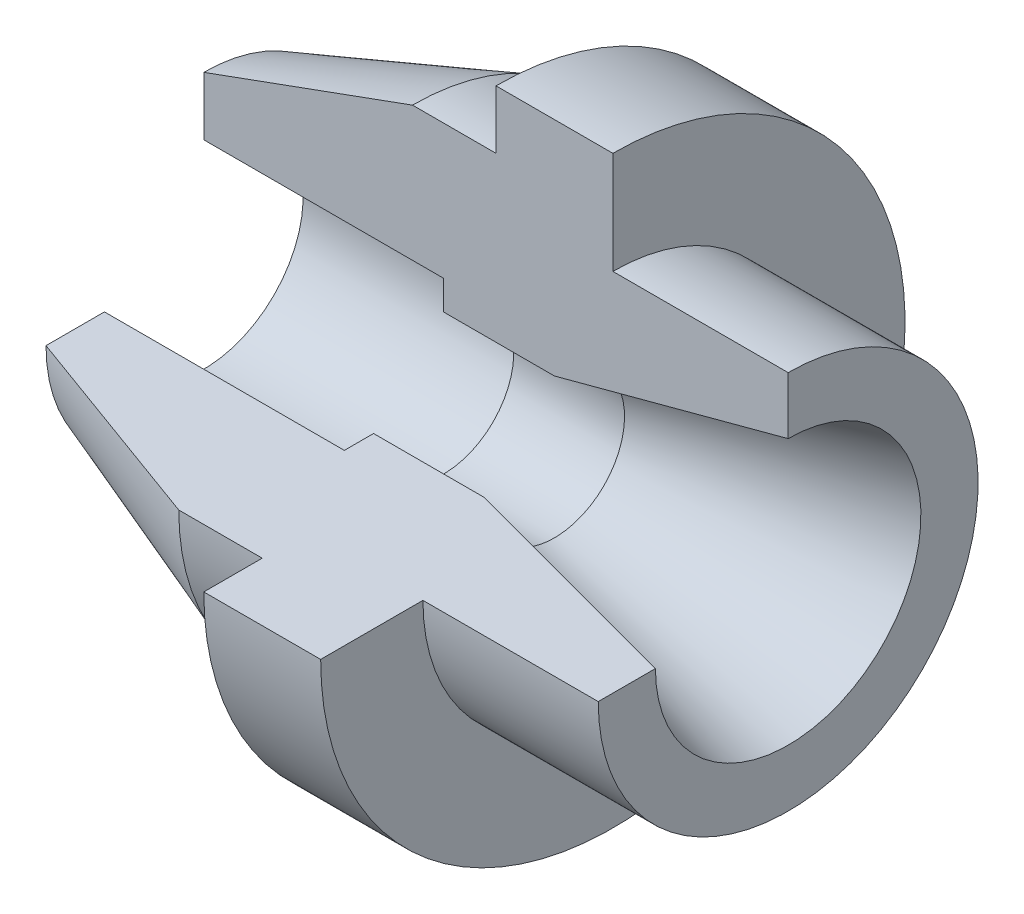
from build123d import *

# Parameters (mm, degrees)
REVOLVE1_ANGLE = 270


with BuildPart() as part:
    # Sketch2 → Revolve1 (revolve)
    with BuildSketch(Plane.XY):
        Polygon((-54.522496773, 27), (-54.522496773, 0), (45.477503227, 0), (45.477503227, 32.5), (15.477503227, 32.5), (15.477503227, 50), (-4.522496773, 50), (-4.522496773, 40), (-18.80529032, 40), align=None)
    revolve(axis=Axis((88.99, 0, 0), (-1, 0, 0)), revolution_arc=REVOLVE1_ANGLE)

    # Sketch3 → Cut-Revolve1 (revolve, cut)
    with BuildSketch(Plane.XY):
        Polygon((-54.522496773, 0), (45.477503227, 0), (45.477503227, 22.717967697), (5.477503227, 12), (-13.471731936, 12), (-13.471731936, 17), (-54.522496773, 17), align=None)
    revolve(axis=Axis((-54.522496773, 0, 0), (1, 0, 0)), mode=Mode.SUBTRACT)


solid = part.part
